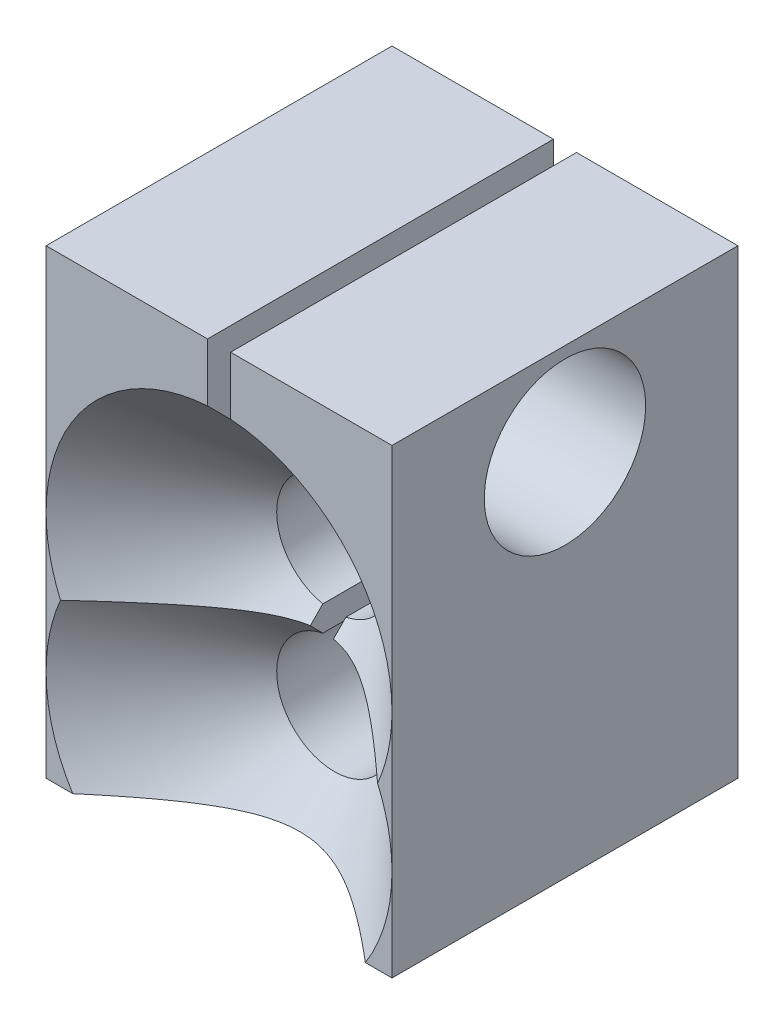
from build123d import *

# Parameters (mm, degrees)
SZKIC1_W                                             = 15
SZKIC1_H                                             = 15
DODANIE_WYCI_GNI_CIE1_DEPTH                          = 20
POG_BIENIE_WALCOWE_POD_M3_WKR_T_DO_CZ_CI_D           = 3.6
POG_BIENIE_WALCOWE_POD_M3_WKR_T_DO_CZ_CI_CBORE_D     = 7
POG_BIENIE_WALCOWE_POD_M3_WKR_T_DO_CZ_CI_CBORE_DEPTH = 5
POG_BIENIE_STO_KOWE_POD_M5_WKR_T_DO_CZ_C_D           = 5
POG_BIENIE_STO_KOWE_POD_M5_WKR_T_DO_CZ_C_CSINK_D     = 15
POG_BIENIE_STO_KOWE_POD_M5_WKR_T_DO_CZ_C_CSINK_ANGLE = 90
SZKIC3_W                                             = 1
SZKIC3_H                                             = 13.577845222
WYTNIJ_WYCI_GNI_CIE1_DEPTH                           = 16


with BuildPart() as part:
    # Szkic1 → Dodanie-wyciągnięcie1 (new body)
    with BuildSketch(Plane(origin=(0, 0, 0), x_dir=(1, 0, 0), z_dir=(0, 1, 0))):
        Rectangle(SZKIC1_W, SZKIC1_H)
    extrude(amount=DODANIE_WYCI_GNI_CIE1_DEPTH)

    # Pogłębienie walcowe pod M3 wkręt do części metalowych z łbem stożkowym ściętym2 (through all)
    with Locations(Plane(origin=(7.5, 0, 0), x_dir=(0, 0, -1), z_dir=(1, 0, 0))):
        with Locations((0, 16)):
            CounterBoreHole(POG_BIENIE_WALCOWE_POD_M3_WKR_T_DO_CZ_CI_D / 2, POG_BIENIE_WALCOWE_POD_M3_WKR_T_DO_CZ_CI_CBORE_D / 2, POG_BIENIE_WALCOWE_POD_M3_WKR_T_DO_CZ_CI_CBORE_DEPTH)

    # Pogłębienie stożkowe pod M5 wkręt do części metalowych z łbem soczewkowym1 (through all)
    with Locations(Plane.XY.offset(7.5)):
        with Locations((0, 10), (0, 4)):
            CounterSinkHole(POG_BIENIE_STO_KOWE_POD_M5_WKR_T_DO_CZ_C_D / 2, POG_BIENIE_STO_KOWE_POD_M5_WKR_T_DO_CZ_C_CSINK_D / 2, counter_sink_angle=POG_BIENIE_STO_KOWE_POD_M5_WKR_T_DO_CZ_C_CSINK_ANGLE)

    # Szkic3 → Wytnij-wyciągnięcie1 (cut, through all)
    with BuildSketch(Plane.XY.offset(7.5)):
        with Locations((0, 13.211077389)):
            Rectangle(SZKIC3_W, SZKIC3_H)
    extrude(amount=-WYTNIJ_WYCI_GNI_CIE1_DEPTH, mode=Mode.SUBTRACT)


solid = part.part
